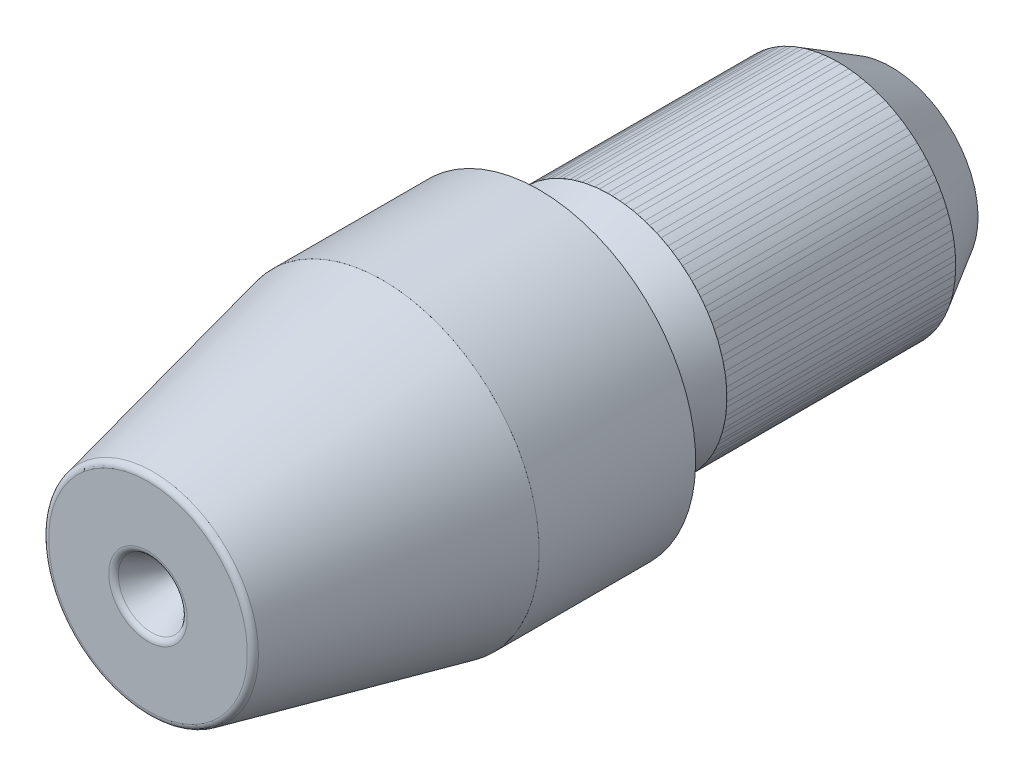
from build123d import *

# Parameters (mm, degrees)
SKETCH10_R          = 0.9
CUT_EXTRUDE2_DEPTH  = 1.2
CUT_EXTRUDE2_TAPER  = 30
SKETCH15_R          = 0.9
CUT_EXTRUDE5_DEPTH  = 1.2
CUT_EXTRUDE5_TAPER  = 30
FILLET1_R           = 0.16
FILLET3_R           = 0.18
SKETCH17_R          = 4.001
SKETCH17_R_2        = 4
BOSS_EXTRUDE1_DEPTH = 4
SKETCH19_R          = 3.001
SKETCH19_R_2        = 3
BOSS_EXTRUDE2_DEPTH = 5.85


with BuildPart() as part:
    # Sketch3 → Revolve2 (revolve)
    with BuildSketch(Plane(origin=(0, 0, 0), x_dir=(0, 0, -1), z_dir=(1, 0, 0))):
        Polygon((-9.5, 0), (-9.5, 2.669832024), (-3.5, 4), (0.5, 4), (0.5, 3), (9.5, 3), (9.5, 0), align=None)
    revolve(axis=Axis((0, 0, -9.5), (0, 0, 1)))

    # Sketch16 → Cut-Revolve1 (revolve, cut)
    with BuildSketch(Plane(origin=(0, 0, 0), x_dir=(0, 0, -1), z_dir=(1, 0, 0))):
        with BuildLine():
            Line((0.5, 3), (0.391746825, 2.8125))
            ThreePointArc((0.391746825, 2.8125), (0.391746825, 2.6875), (0.5, 2.625))
            Line((0.5, 2.625), (1.137450732, 2.625))
            ThreePointArc((1.137450732, 2.625), (1.267686865, 2.636394185), (1.39396584, 2.670230534))
            Line((1.39396584, 2.670230534), (2.3, 3))
            Line((2.3, 3), (0.5, 3))
        make_face()
        Polygon((8.15, 3), (9.5, 2.220577137), (9.5, 3), align=None)
    revolve(axis=Axis((0, 0, 9.5), (0, 0, -1)), mode=Mode.SUBTRACT)

    # Sketch10 → Cut-Extrude2 (cut)
    with BuildSketch(Plane.XY.offset(9.5)):
        Circle(SKETCH10_R)
    extrude(amount=-CUT_EXTRUDE2_DEPTH, taper=CUT_EXTRUDE2_TAPER, mode=Mode.SUBTRACT)

    # Sketch15 → Cut-Extrude5 (cut)
    with BuildSketch(Plane(origin=(0, 0, -9.5), x_dir=(-1, 0, 0), z_dir=(0, 0, -1))):
        Circle(SKETCH15_R)
    extrude(amount=-CUT_EXTRUDE5_DEPTH, taper=CUT_EXTRUDE5_TAPER, mode=Mode.SUBTRACT)

    # Fillet1
    fillet1_edges = [part.edges().sort_by_distance(p)[0] for p in [
        (0, -2.669832024, 9.5),
    ]]
    fillet(fillet1_edges, radius=FILLET1_R)

    # Fillet3
    fillet3_edges = [part.edges().sort_by_distance(p)[0] for p in [
        (-0.9, 0, 9.5),
        (0.9, 0, -9.5),
    ]]
    fillet(fillet3_edges, radius=FILLET3_R)


with BuildPart() as body_2:
    # Sketch17 → Boss-Extrude1 (new body)
    with BuildSketch(Plane(origin=(0, 0, -0.5), x_dir=(-1, 0, 0), z_dir=(0, 0, -1))):
        Circle(SKETCH17_R)
        Circle(SKETCH17_R_2, mode=Mode.SUBTRACT)
    extrude(amount=-BOSS_EXTRUDE1_DEPTH)


with BuildPart() as body_3:
    # Sketch19 → Boss-Extrude2 (new body)
    with BuildSketch(Plane(origin=(0, 0, -8.15), x_dir=(-1, 0, 0), z_dir=(0, 0, -1))):
        Circle(SKETCH19_R)
        Circle(SKETCH19_R_2, mode=Mode.SUBTRACT)
    extrude(amount=-BOSS_EXTRUDE2_DEPTH)


solid = Compound([part.part, body_2.part, body_3.part])
